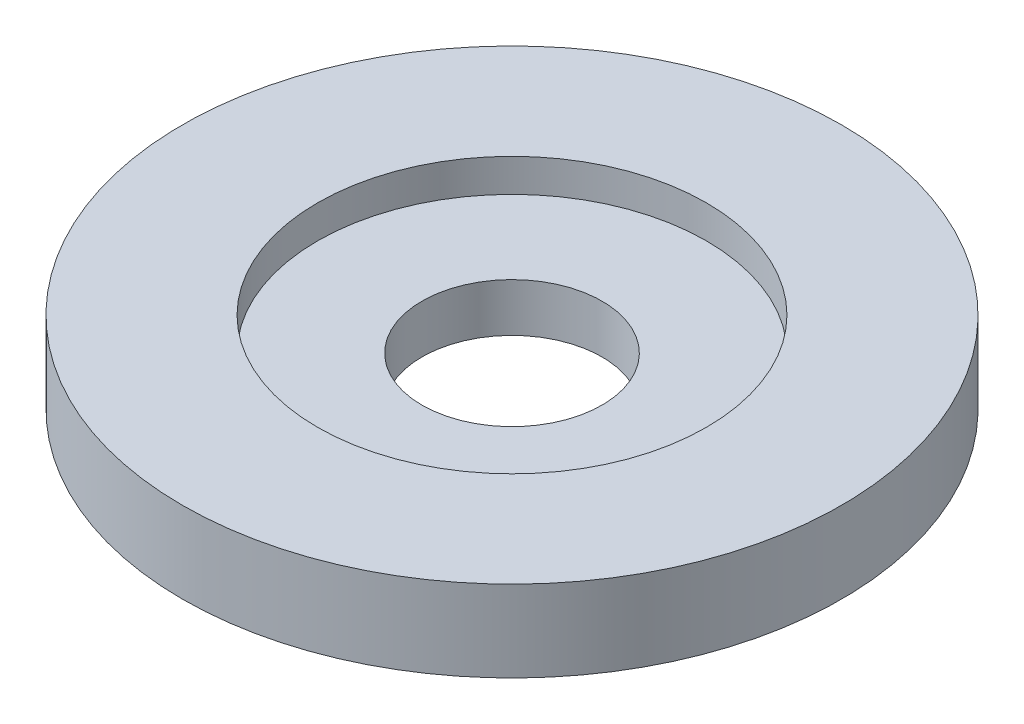
from build123d import *

# Parameters (mm, degrees)
SKETCH1_R           = 19.05
BOSS_EXTRUDE1_DEPTH = 4.699
SKETCH2_R           = 11.2395
CUT_EXTRUDE1_DEPTH  = 1.905
SKETCH3_R           = 5.207
CUT_EXTRUDE2_DEPTH  = 3.175


with BuildPart() as part:
    # Sketch1 → Boss-Extrude1 (new body)
    with BuildSketch(Plane(origin=(0, 0, 0), x_dir=(1, 0, 0), z_dir=(0, 1, 0))):
        Circle(SKETCH1_R)
    extrude(amount=-BOSS_EXTRUDE1_DEPTH)

    # Sketch2 → Cut-Extrude1 (cut)
    with BuildSketch(Plane(origin=(0, 0, 0), x_dir=(1, 0, 0), z_dir=(0, 1, 0))):
        Circle(SKETCH2_R)
    extrude(amount=-CUT_EXTRUDE1_DEPTH, mode=Mode.SUBTRACT)

    # Sketch3 → Cut-Extrude2 (cut)
    with BuildSketch(Plane(origin=(0, -1.905, 0), x_dir=(1, 0, 0), z_dir=(0, 1, 0))):
        Circle(SKETCH3_R)
    extrude(amount=-CUT_EXTRUDE2_DEPTH, mode=Mode.SUBTRACT)


solid = part.part
